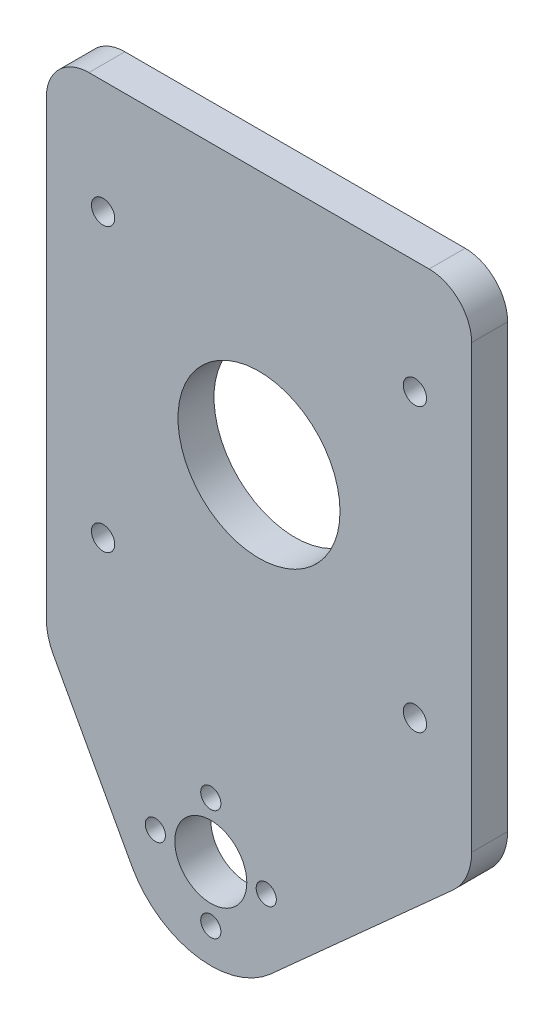
from build123d import *

# Parameters (mm, degrees)
SKETCH1_W           = 304.8
SKETCH1_H           = 89.8
SKETCH1_R           = 14.2875
SKETCH1_R_2         = 2.54
SKETCH1_R_3         = 17.145
BOSS_EXTRUDE1_DEPTH = 6.35
SKETCH2_W           = 114.9
SKETCH2_H           = 89.8
SKETCH2_R           = 2.54
SKETCH2_R_2         = 17.145
CUT_EXTRUDE1_DEPTH  = 10
SKETCH4_R           = 6.35
SKETCH4_R_2         = 1.778
BOSS_EXTRUDE2_DEPTH = 6.35
FILLET1_R           = 10
FILLET2_R           = 7.5
SKETCH7_R           = 2.05
CUT_EXTRUDE2_DEPTH  = 10
SCALE1_SCALE        = 0.333333333


with BuildPart() as part:
    # Sketch1 → Boss-Extrude1 (new body)
    with BuildSketch(Plane.XY):
        with Locations((152.4, 44.9)):
            Rectangle(SKETCH1_W, SKETCH1_H)
        with Locations((152.4, 44.9)):
            Circle(SKETCH1_R, mode=Mode.SUBTRACT)
        with Locations((109.401585406, 62.859439014)):
            Circle(SKETCH1_R_2, mode=Mode.SUBTRACT)
        with Locations((109.399439014, 26.938414594)):
            Circle(SKETCH1_R_2, mode=Mode.SUBTRACT)
        with Locations((73.478414594, 26.940560986)):
            Circle(SKETCH1_R_2, mode=Mode.SUBTRACT)
        with Locations((73.480560986, 62.861585406)):
            Circle(SKETCH1_R_2, mode=Mode.SUBTRACT)
        with Locations((91.44, 44.9)):
            Circle(SKETCH1_R_3, mode=Mode.SUBTRACT)
        with Locations((195.400560986, 62.861585406)):
            Circle(SKETCH1_R_2, mode=Mode.SUBTRACT)
        with Locations((231.321585406, 62.859439014)):
            Circle(SKETCH1_R_2, mode=Mode.SUBTRACT)
        with Locations((231.319439014, 26.938414594)):
            Circle(SKETCH1_R_2, mode=Mode.SUBTRACT)
        with Locations((195.398414594, 26.940560986)):
            Circle(SKETCH1_R_2, mode=Mode.SUBTRACT)
        with Locations((213.36, 44.9)):
            Circle(SKETCH1_R_3, mode=Mode.SUBTRACT)
    extrude(amount=BOSS_EXTRUDE1_DEPTH)

    # Sketch2 → Cut-Extrude1 (cut)
    with BuildSketch(Plane.XY.offset(6.35)):
        with Locations((247.35, 44.9)):
            Rectangle(SKETCH2_W, SKETCH2_H)
        with Locations((195.398414594, 26.940560986)):
            Circle(SKETCH2_R, mode=Mode.SUBTRACT)
        with Locations((231.319439014, 26.938414594)):
            Circle(SKETCH2_R, mode=Mode.SUBTRACT)
        with Locations((213.36, 44.9)):
            Circle(SKETCH2_R_2, mode=Mode.SUBTRACT)
        with Locations((195.400560986, 62.861585406)):
            Circle(SKETCH2_R, mode=Mode.SUBTRACT)
        with Locations((231.321585406, 62.859439014)):
            Circle(SKETCH2_R, mode=Mode.SUBTRACT)
        with Locations((57.45, 44.9)):
            Rectangle(SKETCH2_W, SKETCH2_H)
        with Locations((73.478414594, 26.940560986)):
            Circle(SKETCH2_R, mode=Mode.SUBTRACT)
        with Locations((109.399439014, 26.938414594)):
            Circle(SKETCH2_R, mode=Mode.SUBTRACT)
        with Locations((91.44, 44.9)):
            Circle(SKETCH2_R_2, mode=Mode.SUBTRACT)
        with Locations((73.480560986, 62.861585406)):
            Circle(SKETCH2_R, mode=Mode.SUBTRACT)
        with Locations((109.401585406, 62.859439014)):
            Circle(SKETCH2_R, mode=Mode.SUBTRACT)
    extrude(amount=-CUT_EXTRUDE1_DEPTH, mode=Mode.SUBTRACT)

    # Sketch4 → Boss-Extrude2 (add)
    with BuildSketch(Plane.XY.offset(6.35)):
        with BuildLine():
            Line((189.9, 0), (154.512001483, -31.80682216))
            ThreePointArc((154.512001483, -31.80682216), (141.221457874, -35.647397134), (129.96508312, -27.604848226))
            Line((129.96508312, -27.604848226), (114.9, 0))
            Line((114.9, 0), (189.9, 0))
        make_face()
        with Locations((143.9, -20)):
            Circle(SKETCH4_R, mode=Mode.SUBTRACT)
        with Locations((143.9, -29.779)):
            Circle(SKETCH4_R_2, mode=Mode.SUBTRACT)
        with Locations((134.121, -20)):
            Circle(SKETCH4_R_2, mode=Mode.SUBTRACT)
        with Locations((153.679, -20)):
            Circle(SKETCH4_R_2, mode=Mode.SUBTRACT)
        with Locations((143.9, -10.221)):
            Circle(SKETCH4_R_2, mode=Mode.SUBTRACT)
    extrude(amount=-BOSS_EXTRUDE2_DEPTH)

    # Fillet1
    fillet1_edges = [part.edges().sort_by_distance(p)[0] for p in [
        (189.9, 0, 3.175),
        (114.9, 0, 3.175),
    ]]
    fillet(fillet1_edges, radius=FILLET1_R)

    # Fillet2
    fillet2_edges = [part.edges().sort_by_distance(p)[0] for p in [
        (114.9, 89.8, 3.175),
        (189.9, 89.8, 3.175),
    ]]
    fillet(fillet2_edges, radius=FILLET2_R)

    # Sketch7 → Cut-Extrude2 (cut)
    with BuildSketch(Plane.XY.offset(6.35)):
        with Locations((179.9, 69.8)):
            Circle(SKETCH7_R)
        with Locations((124.9, 69.8)):
            Circle(SKETCH7_R)
        with Locations((124.9, 20)):
            Circle(SKETCH7_R)
        with Locations((179.9, 20)):
            Circle(SKETCH7_R)
    extrude(amount=-CUT_EXTRUDE2_DEPTH, mode=Mode.SUBTRACT)


with BuildPart() as part_1:
    # Scale1: scaled about (151.749134019, 33.595748841, 3.175)
    add(part.part.scale(SCALE1_SCALE).moved(Location((101.166089346, 22.397165894, 2.116666667))))


solid = part_1.part
